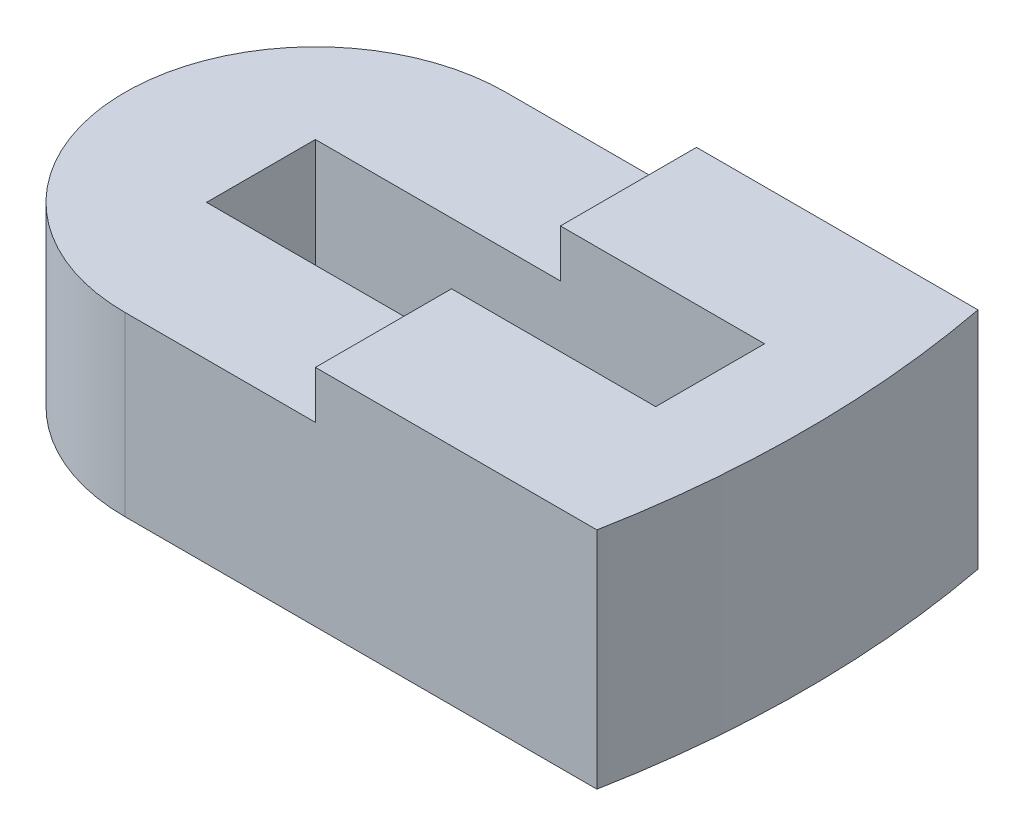
from build123d import *

# Parameters (mm, degrees)
SKETCH1_W           = 33
SKETCH1_H           = 8
BOSS_EXTRUDE1_DEPTH = 3
BOSS_EXTRUDE2_DEPTH = 16.5
BOSS_EXTRUDE3_DEPTH = 13


with BuildPart() as part:
    # Sketch1 → Boss-Extrude1 (new body)
    with BuildSketch(Plane(origin=(0, 0, 0), x_dir=(1, 0, 0), z_dir=(0, 1, 0))):
        with Locations((41.871824735, 0)):
            Rectangle(SKETCH1_W, SKETCH1_H)
    extrude(amount=BOSS_EXTRUDE1_DEPTH)

    # Sketch1_6 → Boss-Extrude2 (add)
    with BuildSketch(Plane(origin=(0, 0, 0), x_dir=(1, 0, 0), z_dir=(0, 1, 0))):
        with BuildLine():
            Line((58.371824735, 4), (58.371824735, -4))
            Line((58.371824735, -4), (43.371824735, -4))
            Line((43.371824735, -4), (43.371824735, -14))
            Line((43.371824735, -14), (64.053572815, -14))
            ThreePointArc((64.053572815, -14), (65.371824735, 0), (64.053572815, 14))
            Line((64.053572815, 14), (43.371824735, 14))
            Line((43.371824735, 14), (43.371824735, 4))
            Line((43.371824735, 4), (58.371824735, 4))
        make_face()
    extrude(amount=BOSS_EXTRUDE2_DEPTH)

    # Sketch1_7 → Boss-Extrude3 (add)
    with BuildSketch(Plane(origin=(0, 0, 0), x_dir=(1, 0, 0), z_dir=(0, 1, 0))):
        with BuildLine():
            Line((25.371824735, -4), (25.371824735, 4))
            Line((25.371824735, 4), (43.371824735, 4))
            Line((43.371824735, 4), (43.371824735, 14))
            Line((43.371824735, 14), (29.371824735, 14))
            ThreePointArc((29.371824735, 14), (15.371824735, 0), (29.371824735, -14))
            Line((29.371824735, -14), (43.371824735, -14))
            Line((43.371824735, -14), (43.371824735, -4))
            Line((43.371824735, -4), (25.371824735, -4))
        make_face()
    extrude(amount=BOSS_EXTRUDE3_DEPTH)


solid = part.part
